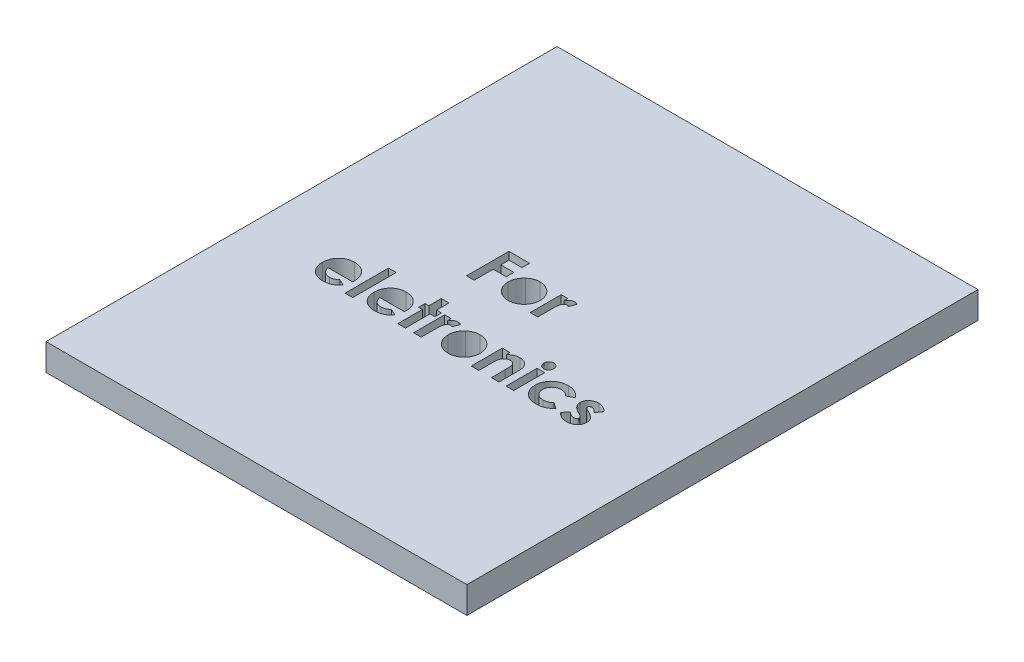
from build123d import *

# Parameters (mm, degrees)
SKETCH1_W           = 63
SKETCH1_H           = 81.5
BOSS_EXTRUDE1_DEPTH = 4
SKETCH2_W           = 1.13974359
SKETCH2_H           = 6.512820513
SKETCH2_H_2         = 4.640384615
CUT_EXTRUDE1_DEPTH  = 5
SKETCH3_W           = 63
SKETCH3_H           = 5
CUT_EXTRUDE2_DEPTH  = 5.0000001


with BuildPart() as part:
    # Sketch1 → Boss-Extrude1 (new body)
    with BuildSketch(Plane(origin=(0, 0, 0), x_dir=(1, 0, 0), z_dir=(0, 1, 0))):
        with Locations((-31.5, 40.75)):
            Rectangle(SKETCH1_W, SKETCH1_H)
    extrude(amount=BOSS_EXTRUDE1_DEPTH)

    # Sketch2 → Cut-Extrude1 (cut, through all)
    with BuildSketch(Plane(origin=(0, 4, 0), x_dir=(1, 0, 0), z_dir=(0, 1, 0))):
        Polygon((-40.055769231, 46.35), (-36.962179487, 46.35), (-36.962179487, 45.21025641), (-38.916025641, 45.21025641), (-38.916025641, 43.989102564), (-36.962179487, 43.989102564), (-36.962179487, 42.849358974), (-38.916025641, 42.849358974), (-38.916025641, 40), (-40.055769231, 40), align=None)
        with BuildLine():
            add(Edge.make_bspline(
                [(-33.774459135, 44.721794872), (-33.720574258, 44.720835954), (-33.613857786, 44.718936861), (-33.454916932, 44.703128649), (-33.298754731, 44.677336899), (-33.144473583, 44.643941085), (-32.993506133, 44.597148555), (-32.845060574, 44.541028151), (-32.697809615, 44.476595363), (-32.555407996, 44.399897809), (-32.41682697, 44.316712317), (-32.28544391, 44.224951894), (-32.162349862, 44.125337286), (-32.045259781, 44.020178138), (-31.939630254, 43.904896162), (-31.838710987, 43.785046127), (-31.747954402, 43.656334226), (-31.663926878, 43.52189687), (-31.589117778, 43.382511483), (-31.524159832, 43.239147681), (-31.467782443, 43.093787568), (-31.423640077, 42.944660559), (-31.387094267, 42.793733092), (-31.364031263, 42.639155664), (-31.347635066, 42.482516174), (-31.345796533, 42.377053579), (-31.344871795, 42.324008413)],
                knots=[0, 0, 0, 0, 0.000161629, 0.000320098, 0.000478613, 0.000636315, 0.000793245, 0.000952249, 0.001112273, 0.001275019, 0.001437107, 0.001596964, 0.001755296, 0.001911968, 0.002068568, 0.002223944, 0.002381722, 0.002540559, 0.002699339, 0.002855882, 0.003012508, 0.003166634, 0.00332214, 0.003477942, 0.003635146, 0.003794231, 0.003794231, 0.003794231, 0.003794231], degree=3))
            add(Edge.make_bspline(
                [(-31.344871795, 42.324008413), (-31.345847703, 42.270548833), (-31.347788029, 42.164259068), (-31.363438069, 42.006146189), (-31.389328541, 41.850841856), (-31.42285253, 41.697431143), (-31.469469949, 41.547877088), (-31.523937427, 41.399975204), (-31.5907984, 41.255741451), (-31.664718132, 41.113602373), (-31.749285917, 40.977740689), (-31.839963942, 40.847739406), (-31.940460509, 40.727009066), (-32.045244443, 40.611805488), (-32.159285882, 40.50602434), (-32.280764512, 40.407948017), (-32.408628665, 40.316377495), (-32.543797819, 40.233461189), (-32.684540684, 40.160605587), (-32.828483657, 40.094920317), (-32.976468437, 40.04023264), (-33.128188761, 39.995636345), (-33.283736643, 39.96110655), (-33.442768673, 39.937650049), (-33.604942355, 39.921336324), (-33.714208595, 39.919511164), (-33.769370994, 39.918589744)],
                knots=[0, 0, 0, 0, 0.000160357, 0.000318826, 0.000476086, 0.000632547, 0.000789477, 0.000945652, 0.001105038, 0.001266065, 0.001425982, 0.001584798, 0.001741155, 0.00189689, 0.002051692, 0.002207245, 0.002365023, 0.002523191, 0.002682501, 0.002840202, 0.00299757, 0.003155354, 0.003314297, 0.003475128, 0.003637396, 0.003802839, 0.003802839, 0.003802839, 0.003802839], degree=3))
            add(Edge.make_bspline(
                [(-33.769370994, 39.918589744), (-33.850029668, 39.920957235), (-34.009009143, 39.925623596), (-34.243148324, 39.957586948), (-34.468078786, 40.012604259), (-34.68416705, 40.089297176), (-34.891693822, 40.187576291), (-35.088847972, 40.309211621), (-35.277590648, 40.451808514), (-35.454652683, 40.614161729), (-35.616865495, 40.792277907), (-35.758577902, 40.982415842), (-35.878903203, 41.181725686), (-35.977733143, 41.390434719), (-36.054009704, 41.608829137), (-36.109094394, 41.836256018), (-36.141096826, 42.073354625), (-36.145723721, 42.234446258), (-36.148076923, 42.316376202)],
                knots=[0, 0, 0, 0, 0.000241958, 0.000476902, 0.000707365, 0.000935486, 0.001163649, 0.0013949, 0.00162921, 0.001872306, 0.002114544, 0.002350889, 0.002582568, 0.00281188, 0.003042399, 0.003275335, 0.0035128, 0.00375857, 0.00375857, 0.00375857, 0.00375857], degree=3))
            add(Edge.make_bspline(
                [(-36.148076923, 42.316376202), (-36.145641657, 42.403859422), (-36.140855192, 42.575805939), (-36.102848546, 42.827711506), (-36.042156033, 43.068899148), (-35.955035753, 43.298694186), (-35.843747258, 43.517520447), (-35.707889227, 43.724916402), (-35.546790242, 43.920929029), (-35.423420678, 44.039484185), (-35.360687099, 44.099769631)],
                knots=[0, 0, 0, 0, 0.000262348, 0.000515639, 0.000762454, 0.001007214, 0.001251266, 0.001497528, 0.001749652, 0.002010496, 0.002010496, 0.002010496, 0.002010496], degree=3))
            add(Edge.make_bspline(
                [(-35.360687099, 44.099769631), (-35.30312277, 44.149739485), (-35.189560266, 44.248319662), (-35.005058572, 44.373352456), (-34.816149657, 44.481342644), (-34.620569366, 44.570130664), (-34.417772471, 44.637075398), (-34.208798193, 44.685805175), (-33.993689983, 44.715736432), (-33.847907452, 44.719765129), (-33.774459135, 44.721794872)],
                knots=[0, 0, 0, 0, 0.000228503, 0.000450789, 0.000667259, 0.000880757, 0.001093951, 0.001306852, 0.001523808, 0.001744105, 0.001744105, 0.001744105, 0.001744105], degree=3))
        make_face()
        with BuildLine():
            Line((-30.530769231, 44.640384615), (-29.553846154, 44.640384615))
            Line((-29.553846154, 44.640384615), (-29.553846154, 44.069240785))
            add(Edge.make_bspline(
                [(-29.553846154, 44.069240785), (-29.526210875, 44.119998495), (-29.472196577, 44.219206543), (-29.372967782, 44.352373702), (-29.258969722, 44.464523368), (-29.134298701, 44.558001253), (-28.998576866, 44.630858085), (-28.855438606, 44.682777764), (-28.706108465, 44.71651836), (-28.604240505, 44.72002337), (-28.552754407, 44.721794872)],
                knots=[0, 0, 0, 0, 0.00017324, 0.000338604, 0.000496013, 0.000651457, 0.000804551, 0.000956265, 0.001107209, 0.001261461, 0.001261461, 0.001261461, 0.001261461], degree=3))
            add(Edge.make_bspline(
                [(-28.552754407, 44.721794872), (-28.515369076, 44.720044258), (-28.439239191, 44.716479383), (-28.323206534, 44.695756709), (-28.20549973, 44.658286175), (-28.12803851, 44.624548939), (-28.088461538, 44.607311699)],
                knots=[0, 0, 0, 0, 0.000112199, 0.000228477, 0.000352395, 0.000481849, 0.000481849, 0.000481849, 0.000481849], degree=3))
            Line((-28.088461538, 44.607311699), (-28.44208734, 43.641836939))
            add(Edge.make_bspline(
                [(-28.44208734, 43.641836939), (-28.473696437, 43.657108926), (-28.533109371, 43.685814384), (-28.619366635, 43.71968978), (-28.697648679, 43.740358892), (-28.747278057, 43.743442904), (-28.770272436, 43.744871795)],
                knots=[0, 0, 0, 0, 0.00010528, 0.000197885, 0.000277791, 0.000346775, 0.000346775, 0.000346775, 0.000346775], degree=3))
            add(Edge.make_bspline(
                [(-28.770272436, 43.744871795), (-28.791983601, 43.743924936), (-28.834693203, 43.742062303), (-28.897731382, 43.726100166), (-28.957100218, 43.698573954), (-29.015660695, 43.663310146), (-29.068793039, 43.614290815), (-29.121892564, 43.557542236), (-29.168686709, 43.487478566), (-29.218068103, 43.409494144), (-29.260114594, 43.314041281), (-29.296168165, 43.200090234), (-29.328292187, 43.06632251), (-29.350397899, 42.912027868), (-29.371763958, 42.738699375), (-29.384481561, 42.545064821), (-29.393960152, 42.331736498), (-29.394539704, 42.18282563), (-29.394841747, 42.105218349)],
                knots=[0, 0, 0, 0, 6.5073e-05, 0.00012801, 0.000193492, 0.00026091, 0.00033211, 0.000409547, 0.00049354, 0.000584292, 0.000686198, 0.000805268, 0.000942565, 0.001098367, 0.001272557, 0.001466412, 0.0016803, 0.001913096, 0.001913096, 0.001913096, 0.001913096], degree=3))
            Line((-29.394841747, 42.105218349), (-29.391025641, 41.878796074))
            Line((-29.391025641, 41.878796074), (-29.391025641, 40))
            Line((-29.391025641, 40), (-30.530769231, 40))
            Line((-30.530769231, 40), (-30.530769231, 44.640384615))
        make_face()
        with BuildLine():
            Line((-47.793559696, 30.696153846), (-51.453205128, 30.696153846))
            add(Edge.make_bspline(
                [(-51.453205128, 30.696153846), (-51.445743407, 30.653630842), (-51.431080535, 30.570069785), (-51.399239588, 30.448690099), (-51.358605765, 30.334303931), (-51.309908686, 30.226758376), (-51.253969385, 30.125484882), (-51.188720825, 30.030958461), (-51.114990624, 29.943262606), (-51.033205071, 29.862778452), (-50.944727382, 29.790662906), (-50.849986641, 29.727485128), (-50.748885083, 29.675683216), (-50.642581798, 29.632019579), (-50.530282456, 29.597433555), (-50.41182178, 29.573580232), (-50.287513793, 29.559489986), (-50.202831395, 29.557451994), (-50.159545272, 29.556410256)],
                knots=[0, 0, 0, 0, 0.000129479, 0.000254437, 0.000375941, 0.000493217, 0.000608243, 0.000722564, 0.000837223, 0.000951459, 0.001066288, 0.001179184, 0.001292402, 0.001406496, 0.001523586, 0.001644328, 0.001768507, 0.001898354, 0.001898354, 0.001898354, 0.001898354], degree=3))
            add(Edge.make_bspline(
                [(-50.159545272, 29.556410256), (-50.107295984, 29.557789688), (-50.004401749, 29.560506195), (-49.853660927, 29.58459758), (-49.707872595, 29.620986557), (-49.568416423, 29.67510002), (-49.433677031, 29.74246177), (-49.305872643, 29.826386221), (-49.182791064, 29.924420827), (-49.107696797, 29.999985864), (-49.069411058, 30.038511619)],
                knots=[0, 0, 0, 0, 0.000156646, 0.000308483, 0.000456881, 0.000606657, 0.000756272, 0.000907985, 0.001064529, 0.001227354, 0.001227354, 0.001227354, 0.001227354], degree=3))
            Line((-49.069411058, 30.038511619), (-48.115384615, 29.584395032))
            add(Edge.make_bspline(
                [(-48.115384615, 29.584395032), (-48.145421581, 29.542888555), (-48.204938724, 29.460644998), (-48.302098463, 29.344907072), (-48.403490837, 29.236918892), (-48.509191464, 29.137390713), (-48.6193344, 29.04660615), (-48.733613254, 28.963459283), (-48.853698164, 28.890182573), (-48.977188054, 28.823230936), (-49.106635688, 28.765833608), (-49.241682829, 28.716887193), (-49.381757474, 28.67264005), (-49.528628466, 28.638926151), (-49.681072809, 28.612238504), (-49.839455182, 28.593286739), (-50.003754709, 28.581581142), (-50.115428141, 28.580193457), (-50.172265625, 28.579487179)],
                knots=[0, 0, 0, 0, 0.000153664, 0.000304479, 0.000452959, 0.000597843, 0.000739702, 0.00088092, 0.001021421, 0.00116142, 0.001302071, 0.001445743, 0.001592199, 0.00174246, 0.001897424, 0.002056307, 0.002220798, 0.002391293, 0.002391293, 0.002391293, 0.002391293], degree=3))
            add(Edge.make_bspline(
                [(-50.172265625, 28.579487179), (-50.259709162, 28.58126989), (-50.430962288, 28.584761226), (-50.681450944, 28.617165821), (-50.919345691, 28.670896133), (-51.145318262, 28.743934239), (-51.358391852, 28.84036742), (-51.558671912, 28.958313201), (-51.748159526, 29.095510323), (-51.92106479, 29.25483819), (-52.078586587, 29.428257102), (-52.21694394, 29.61449717), (-52.332719402, 29.812257207), (-52.42779654, 30.020228395), (-52.501693795, 30.238943059), (-52.554969429, 30.46849664), (-52.587628031, 30.708779502), (-52.591155322, 30.872438953), (-52.592948718, 30.955649038)],
                knots=[0, 0, 0, 0, 0.000262237, 0.000513576, 0.000756131, 0.000993061, 0.001224771, 0.001456243, 0.001689299, 0.001925206, 0.002160258, 0.002391264, 0.002619898, 0.002846449, 0.003076139, 0.003311255, 0.003552503, 0.00380203, 0.00380203, 0.00380203, 0.00380203], degree=3))
            add(Edge.make_bspline(
                [(-52.592948718, 30.955649038), (-52.591137671, 31.040973599), (-52.587574518, 31.208845841), (-52.555250619, 31.454676944), (-52.501546506, 31.689233065), (-52.427433085, 31.912837215), (-52.333798279, 32.12618873), (-52.216549773, 32.327421042), (-52.078655247, 32.51723473), (-51.921700919, 32.694741828), (-51.748063175, 32.854961377), (-51.563556666, 32.997749013), (-51.366108275, 33.11672915), (-51.157951311, 33.212865027), (-50.940417221, 33.290973), (-50.710991617, 33.342947333), (-50.471420076, 33.377844986), (-50.307654246, 33.381058842), (-50.224419071, 33.382692308)],
                knots=[0, 0, 0, 0, 0.000255882, 0.000503435, 0.00074227, 0.000976784, 0.001209135, 0.001439966, 0.001674052, 0.001911946, 0.002149575, 0.00238186, 0.002610703, 0.002839475, 0.003068794, 0.003302672, 0.003544091, 0.003793618, 0.003793618, 0.003793618, 0.003793618], degree=3))
            add(Edge.make_bspline(
                [(-50.224419071, 33.382692308), (-50.13655662, 33.38088194), (-49.964047753, 33.377327468), (-49.711814521, 33.345185991), (-49.472340182, 33.291128039), (-49.24460444, 33.21872148), (-49.031515574, 33.119852295), (-48.828391376, 33.004808973), (-48.640103915, 32.864646231), (-48.464646249, 32.706098063), (-48.306259847, 32.530194365), (-48.167812582, 32.339109074), (-48.050010999, 32.134707069), (-47.954531647, 31.916159458), (-47.880710271, 31.684122341), (-47.827385321, 31.438897064), (-47.794975826, 31.179550909), (-47.79151417, 31.001961732), (-47.78974359, 30.911127804)],
                knots=[0, 0, 0, 0, 0.000263508, 0.000517371, 0.000761167, 0.000999306, 0.001232699, 0.001464632, 0.001698441, 0.001935289, 0.002173082, 0.002407167, 0.00264194, 0.00287946, 0.00312123, 0.003371236, 0.00363141, 0.003903816, 0.003903816, 0.003903816, 0.003903816], degree=3))
            Line((-47.78974359, 30.911127804), (-47.793559696, 30.696153846))
        make_face()
        with Locations((-46.324358974, 31.917307693)):
            Rectangle(SKETCH2_W, SKETCH2_H)
        with BuildLine():
            Line((-40.059585337, 30.696153846), (-43.719230769, 30.696153846))
            add(Edge.make_bspline(
                [(-43.719230769, 30.696153846), (-43.711769048, 30.653630842), (-43.697106176, 30.570069785), (-43.665265229, 30.448690099), (-43.624631406, 30.334303931), (-43.575934328, 30.226758376), (-43.519995026, 30.125484882), (-43.454746466, 30.030958461), (-43.381016265, 29.943262606), (-43.299230712, 29.862778452), (-43.210753023, 29.790662906), (-43.116012282, 29.727485128), (-43.014910724, 29.675683216), (-42.908607439, 29.632019579), (-42.796308097, 29.597433555), (-42.677847421, 29.573580232), (-42.553539434, 29.559489986), (-42.468857036, 29.557451994), (-42.425570913, 29.556410256)],
                knots=[0, 0, 0, 0, 0.000129479, 0.000254437, 0.000375941, 0.000493217, 0.000608243, 0.000722564, 0.000837223, 0.000951459, 0.001066288, 0.001179184, 0.001292402, 0.001406496, 0.001523586, 0.001644328, 0.001768507, 0.001898354, 0.001898354, 0.001898354, 0.001898354], degree=3))
            add(Edge.make_bspline(
                [(-42.425570913, 29.556410256), (-42.373321625, 29.557789688), (-42.27042739, 29.560506195), (-42.119686569, 29.58459758), (-41.973898236, 29.620986557), (-41.834442065, 29.67510002), (-41.699702672, 29.74246177), (-41.571898284, 29.826386221), (-41.448816705, 29.924420827), (-41.373722438, 29.999985864), (-41.335436699, 30.038511619)],
                knots=[0, 0, 0, 0, 0.000156646, 0.000308483, 0.000456881, 0.000606657, 0.000756272, 0.000907985, 0.001064529, 0.001227354, 0.001227354, 0.001227354, 0.001227354], degree=3))
            Line((-41.335436699, 30.038511619), (-40.381410256, 29.584395032))
            add(Edge.make_bspline(
                [(-40.381410256, 29.584395032), (-40.411447222, 29.542888555), (-40.470964365, 29.460644998), (-40.568124104, 29.344907072), (-40.669516478, 29.236918892), (-40.775217105, 29.137390713), (-40.885360041, 29.04660615), (-40.999638895, 28.963459283), (-41.119723805, 28.890182573), (-41.243213695, 28.823230936), (-41.372661329, 28.765833608), (-41.50770847, 28.716887193), (-41.647783115, 28.67264005), (-41.794654107, 28.638926151), (-41.94709845, 28.612238504), (-42.105480823, 28.593286739), (-42.26978035, 28.581581142), (-42.381453782, 28.580193457), (-42.438291266, 28.579487179)],
                knots=[0, 0, 0, 0, 0.000153664, 0.000304479, 0.000452959, 0.000597843, 0.000739702, 0.00088092, 0.001021421, 0.00116142, 0.001302071, 0.001445743, 0.001592199, 0.00174246, 0.001897424, 0.002056307, 0.002220798, 0.002391293, 0.002391293, 0.002391293, 0.002391293], degree=3))
            add(Edge.make_bspline(
                [(-42.438291266, 28.579487179), (-42.525734803, 28.58126989), (-42.696987929, 28.584761226), (-42.947476585, 28.617165821), (-43.185371332, 28.670896133), (-43.411343903, 28.743934239), (-43.624417493, 28.84036742), (-43.824697553, 28.958313201), (-44.014185167, 29.095510323), (-44.187090431, 29.25483819), (-44.344612228, 29.428257102), (-44.482969581, 29.61449717), (-44.598745043, 29.812257207), (-44.693822181, 30.020228395), (-44.767719436, 30.238943059), (-44.82099507, 30.46849664), (-44.853653672, 30.708779502), (-44.857180963, 30.872438953), (-44.858974359, 30.955649038)],
                knots=[0, 0, 0, 0, 0.000262237, 0.000513576, 0.000756131, 0.000993061, 0.001224771, 0.001456243, 0.001689299, 0.001925206, 0.002160258, 0.002391264, 0.002619898, 0.002846449, 0.003076139, 0.003311255, 0.003552503, 0.00380203, 0.00380203, 0.00380203, 0.00380203], degree=3))
            add(Edge.make_bspline(
                [(-44.858974359, 30.955649038), (-44.857163312, 31.040973599), (-44.853600159, 31.208845841), (-44.82127626, 31.454676944), (-44.767572147, 31.689233065), (-44.693458726, 31.912837215), (-44.59982392, 32.12618873), (-44.482575414, 32.327421042), (-44.344680888, 32.51723473), (-44.18772656, 32.694741828), (-44.014088816, 32.854961377), (-43.829582307, 32.997749013), (-43.632133916, 33.11672915), (-43.423976952, 33.212865027), (-43.206442862, 33.290973), (-42.977017258, 33.342947333), (-42.737445717, 33.377844986), (-42.573679887, 33.381058842), (-42.490444712, 33.382692308)],
                knots=[0, 0, 0, 0, 0.000255882, 0.000503435, 0.00074227, 0.000976784, 0.001209135, 0.001439966, 0.001674052, 0.001911946, 0.002149575, 0.00238186, 0.002610703, 0.002839475, 0.003068794, 0.003302672, 0.003544091, 0.003793618, 0.003793618, 0.003793618, 0.003793618], degree=3))
            add(Edge.make_bspline(
                [(-42.490444712, 33.382692308), (-42.402582261, 33.38088194), (-42.230073394, 33.377327468), (-41.977840162, 33.345185991), (-41.738365823, 33.291128039), (-41.510630081, 33.21872148), (-41.297541215, 33.119852295), (-41.094417017, 33.004808973), (-40.906129556, 32.864646231), (-40.730671891, 32.706098063), (-40.572285488, 32.530194365), (-40.433838223, 32.339109074), (-40.31603664, 32.134707069), (-40.220557288, 31.916159458), (-40.146735912, 31.684122341), (-40.093410962, 31.438897064), (-40.061001467, 31.179550909), (-40.057539811, 31.001961732), (-40.055769231, 30.911127804)],
                knots=[0, 0, 0, 0, 0.000263508, 0.000517371, 0.000761167, 0.000999306, 0.001232699, 0.001464632, 0.001698441, 0.001935289, 0.002173082, 0.002407167, 0.00264194, 0.00287946, 0.00312123, 0.003371236, 0.00363141, 0.003903816, 0.003903816, 0.003903816, 0.003903816], degree=3))
            Line((-40.055769231, 30.911127804), (-40.059585337, 30.696153846))
        make_face()
        Polygon((-38.997435897, 35.173717949), (-37.857692308, 35.173717949), (-37.857692308, 33.301282051), (-37.125, 33.301282051), (-37.125, 32.324358974), (-37.857692308, 32.324358974), (-37.857692308, 28.660897436), (-38.997435897, 28.660897436), (-38.997435897, 32.324358974), (-39.567307692, 32.324358974), (-39.567307692, 33.301282051), (-38.997435897, 33.301282051), align=None)
        with BuildLine():
            Line((-36.636538462, 33.301282051), (-35.659615385, 33.301282051))
            Line((-35.659615385, 33.301282051), (-35.659615385, 32.730138221))
            add(Edge.make_bspline(
                [(-35.659615385, 32.730138221), (-35.631980106, 32.78089593), (-35.577965808, 32.880103979), (-35.478737012, 33.013271138), (-35.364738953, 33.125420804), (-35.240067932, 33.218898689), (-35.104346097, 33.291755521), (-34.961207836, 33.3436752), (-34.811877695, 33.377415796), (-34.710009736, 33.380920806), (-34.658523638, 33.382692308)],
                knots=[0, 0, 0, 0, 0.00017324, 0.000338604, 0.000496013, 0.000651457, 0.000804551, 0.000956265, 0.001107209, 0.001261461, 0.001261461, 0.001261461, 0.001261461], degree=3))
            add(Edge.make_bspline(
                [(-34.658523638, 33.382692308), (-34.621138306, 33.380941694), (-34.545008422, 33.377376819), (-34.428975765, 33.356654145), (-34.311268961, 33.319183611), (-34.233807741, 33.285446375), (-34.194230769, 33.268209135)],
                knots=[0, 0, 0, 0, 0.000112199, 0.000228477, 0.000352395, 0.000481849, 0.000481849, 0.000481849, 0.000481849], degree=3))
            Line((-34.194230769, 33.268209135), (-34.547856571, 32.302734375))
            add(Edge.make_bspline(
                [(-34.547856571, 32.302734375), (-34.579465667, 32.318006362), (-34.638878601, 32.346711819), (-34.725135866, 32.380587216), (-34.803417909, 32.401256328), (-34.853047288, 32.40434034), (-34.876041667, 32.405769231)],
                knots=[0, 0, 0, 0, 0.00010528, 0.000197885, 0.000277791, 0.000346775, 0.000346775, 0.000346775, 0.000346775], degree=3))
            add(Edge.make_bspline(
                [(-34.876041667, 32.405769231), (-34.897752832, 32.404822372), (-34.940462434, 32.402959739), (-35.003500612, 32.386997601), (-35.062869449, 32.35947139), (-35.121429926, 32.324207582), (-35.17456227, 32.275188251), (-35.227661795, 32.218439671), (-35.27445594, 32.148376002), (-35.323837334, 32.07039158), (-35.365883825, 31.974938717), (-35.401937396, 31.86098767), (-35.434061418, 31.727219946), (-35.45616713, 31.572925304), (-35.477533189, 31.399596811), (-35.490250792, 31.205962257), (-35.499729382, 30.992633934), (-35.500308935, 30.843723066), (-35.500610978, 30.766115785)],
                knots=[0, 0, 0, 0, 6.5073e-05, 0.00012801, 0.000193492, 0.00026091, 0.00033211, 0.000409547, 0.00049354, 0.000584292, 0.000686198, 0.000805268, 0.000942565, 0.001098367, 0.001272557, 0.001466412, 0.0016803, 0.001913096, 0.001913096, 0.001913096, 0.001913096], degree=3))
            Line((-35.500610978, 30.766115785), (-35.496794872, 30.53969351))
            Line((-35.496794872, 30.53969351), (-35.496794872, 28.660897436))
            Line((-35.496794872, 28.660897436), (-36.636538462, 28.660897436))
            Line((-36.636538462, 28.660897436), (-36.636538462, 33.301282051))
        make_face()
        with BuildLine():
            add(Edge.make_bspline(
                [(-31.413561699, 33.382692308), (-31.359676822, 33.381733389), (-31.25296035, 33.379834297), (-31.094019496, 33.364026085), (-30.937857295, 33.338234335), (-30.783576147, 33.304838521), (-30.632608697, 33.258045991), (-30.484163138, 33.201925587), (-30.336912179, 33.137492799), (-30.19451056, 33.060795245), (-30.055929534, 32.977609753), (-29.924546474, 32.88584933), (-29.801452426, 32.786234722), (-29.684362345, 32.681075573), (-29.578732818, 32.565793598), (-29.477813551, 32.445943563), (-29.387056966, 32.317231662), (-29.303029442, 32.182794306), (-29.228220342, 32.043408919), (-29.163262397, 31.900045117), (-29.106885007, 31.754685004), (-29.062742641, 31.605557995), (-29.026196831, 31.454630528), (-29.003133827, 31.3000531), (-28.986737631, 31.14341361), (-28.984899097, 31.037951014), (-28.983974359, 30.984905849)],
                knots=[0, 0, 0, 0, 0.000161629, 0.000320098, 0.000478613, 0.000636315, 0.000793245, 0.000952249, 0.001112273, 0.001275019, 0.001437107, 0.001596964, 0.001755296, 0.001911968, 0.002068568, 0.002223944, 0.002381722, 0.002540559, 0.002699339, 0.002855882, 0.003012508, 0.003166634, 0.00332214, 0.003477942, 0.003635146, 0.003794231, 0.003794231, 0.003794231, 0.003794231], degree=3))
            add(Edge.make_bspline(
                [(-28.983974359, 30.984905849), (-28.984950267, 30.931446269), (-28.986890594, 30.825156504), (-29.002540633, 30.667043625), (-29.028431105, 30.511739292), (-29.061955094, 30.358328579), (-29.108572513, 30.208774524), (-29.163039992, 30.06087264), (-29.229900964, 29.916638887), (-29.303820696, 29.774499809), (-29.388388481, 29.638638125), (-29.479066506, 29.508636841), (-29.579563073, 29.387906502), (-29.684347007, 29.272702924), (-29.798388446, 29.166921775), (-29.919867076, 29.068845453), (-30.047731229, 28.977274931), (-30.182900383, 28.894358625), (-30.323643248, 28.821503023), (-30.467586221, 28.755817753), (-30.615571001, 28.701130076), (-30.767291326, 28.656533781), (-30.922839207, 28.622003986), (-31.081871237, 28.598547485), (-31.244044919, 28.58223376), (-31.35331116, 28.5804086), (-31.408473558, 28.579487179)],
                knots=[0, 0, 0, 0, 0.000160357, 0.000318826, 0.000476086, 0.000632547, 0.000789477, 0.000945652, 0.001105038, 0.001266065, 0.001425982, 0.001584798, 0.001741155, 0.00189689, 0.002051692, 0.002207245, 0.002365023, 0.002523191, 0.002682501, 0.002840202, 0.00299757, 0.003155354, 0.003314297, 0.003475128, 0.003637396, 0.003802839, 0.003802839, 0.003802839, 0.003802839], degree=3))
            add(Edge.make_bspline(
                [(-31.408473558, 28.579487179), (-31.489132232, 28.581854671), (-31.648111707, 28.586521032), (-31.882250888, 28.618484384), (-32.10718135, 28.673501695), (-32.323269614, 28.750194612), (-32.530796386, 28.848473727), (-32.727950536, 28.970109057), (-32.916693212, 29.11270595), (-33.093755248, 29.275059165), (-33.255968059, 29.453175343), (-33.397680466, 29.643313278), (-33.518005768, 29.842623122), (-33.616835707, 30.051332154), (-33.693112268, 30.269726573), (-33.748196959, 30.497153453), (-33.78019939, 30.734252061), (-33.784826285, 30.895343694), (-33.787179487, 30.977273638)],
                knots=[0, 0, 0, 0, 0.000241958, 0.000476902, 0.000707365, 0.000935486, 0.001163649, 0.0013949, 0.00162921, 0.001872306, 0.002114544, 0.002350889, 0.002582568, 0.00281188, 0.003042399, 0.003275335, 0.0035128, 0.00375857, 0.00375857, 0.00375857, 0.00375857], degree=3))
            add(Edge.make_bspline(
                [(-33.787179487, 30.977273638), (-33.784744222, 31.064756858), (-33.779957756, 31.236703375), (-33.74195111, 31.488608942), (-33.681258597, 31.729796583), (-33.594138317, 31.959591622), (-33.482849822, 32.178417883), (-33.346991792, 32.385813838), (-33.185892806, 32.581826465), (-33.062523242, 32.700381621), (-32.999789663, 32.760667067)],
                knots=[0, 0, 0, 0, 0.000262348, 0.000515639, 0.000762454, 0.001007214, 0.001251266, 0.001497528, 0.001749652, 0.002010496, 0.002010496, 0.002010496, 0.002010496], degree=3))
            add(Edge.make_bspline(
                [(-32.999789663, 32.760667067), (-32.942225334, 32.810636921), (-32.82866283, 32.909217098), (-32.644161136, 33.034249892), (-32.455252221, 33.14224008), (-32.25967193, 33.2310281), (-32.056875036, 33.297972834), (-31.847900757, 33.346702611), (-31.632792547, 33.376633868), (-31.487010017, 33.380662565), (-31.413561699, 33.382692308)],
                knots=[0, 0, 0, 0, 0.000228503, 0.000450789, 0.000667259, 0.000880757, 0.001093951, 0.001306852, 0.001523808, 0.001744105, 0.001744105, 0.001744105, 0.001744105], degree=3))
        make_face()
        with BuildLine():
            Line((-28.007051282, 33.301282051), (-26.867307692, 33.301282051))
            Line((-26.867307692, 33.301282051), (-26.867307692, 32.810276442))
            add(Edge.make_bspline(
                [(-26.867307692, 32.810276442), (-26.802285886, 32.860851743), (-26.678016573, 32.957510974), (-26.489105761, 33.080751986), (-26.310797345, 33.181619805), (-26.139116636, 33.25834503), (-25.97083346, 33.313545531), (-25.803222349, 33.353203797), (-25.633787234, 33.378598075), (-25.519885708, 33.381328296), (-25.462980769, 33.382692308)],
                knots=[0, 0, 0, 0, 0.00024703, 0.000472123, 0.000675982, 0.000861062, 0.001035238, 0.001206477, 0.001377376, 0.001547999, 0.001547999, 0.001547999, 0.001547999], degree=3))
            add(Edge.make_bspline(
                [(-25.462980769, 33.382692308), (-25.405258366, 33.381133525), (-25.291944441, 33.378073502), (-25.125095931, 33.356671126), (-24.965688383, 33.317690618), (-24.81192939, 33.265935047), (-24.665383957, 33.197620662), (-24.524256812, 33.116508413), (-24.391579316, 33.017708206), (-24.309870641, 32.942466712), (-24.268539663, 32.904407051)],
                knots=[0, 0, 0, 0, 0.000173165, 0.000339938, 0.000503457, 0.000664765, 0.000825837, 0.000987721, 0.001152325, 0.001320816, 0.001320816, 0.001320816, 0.001320816], degree=3))
            add(Edge.make_bspline(
                [(-24.268539663, 32.904407051), (-24.235390698, 32.869136875), (-24.168850158, 32.798338388), (-24.085117247, 32.677184042), (-24.013264991, 32.54510363), (-23.954392052, 32.40057356), (-23.910887321, 32.242799734), (-23.877418539, 32.073687835), (-23.858638621, 31.892290959), (-23.856320152, 31.767673017), (-23.855128205, 31.703605769)],
                knots=[0, 0, 0, 0, 0.00014504, 0.000291141, 0.000440274, 0.000595467, 0.000758138, 0.000930522, 0.001112156, 0.001304338, 0.001304338, 0.001304338, 0.001304338], degree=3))
            Line((-23.855128205, 31.703605769), (-23.855128205, 28.660897436))
            Line((-23.855128205, 28.660897436), (-24.994871795, 28.660897436))
            Line((-24.994871795, 28.660897436), (-24.994871795, 30.675801282))
            add(Edge.make_bspline(
                [(-24.994871795, 30.675801282), (-24.995112825, 30.741523935), (-24.995574716, 30.867469202), (-24.999121012, 31.047715806), (-25.006045449, 31.210501897), (-25.012356892, 31.356123861), (-25.024748764, 31.484064642), (-25.035923955, 31.595134204), (-25.053071202, 31.688324915), (-25.075382551, 31.788565507), (-25.114343663, 31.895891391), (-25.17482889, 32.008976941), (-25.251562882, 32.105045637), (-25.341411516, 32.184770969), (-25.444275563, 32.247841018), (-25.558912059, 32.292214727), (-25.684706416, 32.319869511), (-25.772358446, 32.322824412), (-25.817878606, 32.324358974)],
                knots=[0, 0, 0, 0, 0.00019717, 0.000377839, 0.000540784, 0.000685996, 0.000814981, 0.000926377, 0.001020696, 0.001099068, 0.001234264, 0.001361772, 0.001482159, 0.001601107, 0.001720441, 0.001842092, 0.001968337, 0.002104736, 0.002104736, 0.002104736, 0.002104736], degree=3))
            add(Edge.make_bspline(
                [(-25.817878606, 32.324358974), (-25.877079488, 32.321356882), (-25.992887922, 32.315484205), (-26.160381655, 32.271198865), (-26.314221857, 32.195882538), (-26.453151529, 32.091659885), (-26.575847481, 31.962984106), (-26.676903122, 31.809523478), (-26.759789508, 31.634981765), (-26.795431886, 31.507537964), (-26.813882212, 31.441566506)],
                knots=[0, 0, 0, 0, 0.000177471, 0.000347167, 0.000515562, 0.000688306, 0.000865557, 0.001046191, 0.001237386, 0.001442574, 0.001442574, 0.001442574, 0.001442574], degree=3))
            add(Edge.make_bspline(
                [(-26.813882212, 31.441566506), (-26.81846785, 31.420847728), (-26.828694747, 31.374640687), (-26.837105076, 31.296578942), (-26.848804454, 31.203966239), (-26.853187923, 31.095126549), (-26.860810294, 30.970574965), (-26.863629411, 30.830146709), (-26.866453572, 30.674117136), (-26.867013553, 30.565136408), (-26.867307692, 30.507892628)],
                knots=[0, 0, 0, 0, 6.3614e-05, 0.000141873, 0.000235288, 0.000343597, 0.000468419, 0.000609667, 0.000764876, 0.000936605, 0.000936605, 0.000936605, 0.000936605], degree=3))
            Line((-26.867307692, 30.507892628), (-26.867307692, 28.660897436))
            Line((-26.867307692, 28.660897436), (-28.007051282, 28.660897436))
            Line((-28.007051282, 28.660897436), (-28.007051282, 33.301282051))
        make_face()
        with BuildLine():
            add(Edge.make_bspline(
                [(-22.229467147, 35.255128205), (-22.180344207, 35.252718048), (-22.08388658, 35.247985471), (-21.945697904, 35.201853381), (-21.818868705, 35.129450443), (-21.706748175, 35.030111886), (-21.613496804, 34.91148348), (-21.542249292, 34.778671092), (-21.502560272, 34.631519243), (-21.497048054, 34.529868286), (-21.494230769, 34.477914663)],
                knots=[0, 0, 0, 0, 0.000146952, 0.000288554, 0.000432131, 0.000582667, 0.000734844, 0.000882778, 0.001031829, 0.001187646, 0.001187646, 0.001187646, 0.001187646], degree=3))
            add(Edge.make_bspline(
                [(-21.494230769, 34.477914663), (-21.496947256, 34.426343911), (-21.50224046, 34.325855843), (-21.54316276, 34.180701649), (-21.611550643, 34.047953769), (-21.705557293, 33.931087215), (-21.816462289, 33.833348564), (-21.940520173, 33.759631194), (-22.077384601, 33.716065421), (-22.172345497, 33.710937228), (-22.220562901, 33.708333333)],
                knots=[0, 0, 0, 0, 0.000154551, 0.00030115, 0.000448498, 0.000599677, 0.000748418, 0.000889792, 0.001029797, 0.001174216, 0.001174216, 0.001174216, 0.001174216], degree=3))
            add(Edge.make_bspline(
                [(-22.220562901, 33.708333333), (-22.270114644, 33.710734875), (-22.367411448, 33.715450396), (-22.506733556, 33.761690426), (-22.635254333, 33.833523144), (-22.746888484, 33.934891341), (-22.841207792, 34.054362692), (-22.909343184, 34.190267067), (-22.951963557, 34.338425136), (-22.957022558, 34.441581614), (-22.959615385, 34.494451122)],
                knots=[0, 0, 0, 0, 0.000148218, 0.000291032, 0.000435714, 0.000587092, 0.000740271, 0.000889885, 0.001040502, 0.001198853, 0.001198853, 0.001198853, 0.001198853], degree=3))
            add(Edge.make_bspline(
                [(-22.959615385, 34.494451122), (-22.95679368, 34.545146172), (-22.951250849, 34.644729281), (-22.911324087, 34.788609513), (-22.841710279, 34.919189116), (-22.749130605, 35.035645918), (-22.637994872, 35.133131438), (-22.511241811, 35.203335451), (-22.373983149, 35.247562155), (-22.278136547, 35.252580147), (-22.229467147, 35.255128205)],
                knots=[0, 0, 0, 0, 0.000152018, 0.000298616, 0.000443707, 0.000593099, 0.0007428, 0.000884019, 0.001025237, 0.001170923, 0.001170923, 0.001170923, 0.001170923], degree=3))
        make_face()
        with Locations((-22.226923077, 30.981089744)):
            Rectangle(SKETCH2_W, SKETCH2_H_2)
        with BuildLine():
            Line((-16.121153846, 32.354887821), (-17.065004006, 31.835897436))
            add(Edge.make_bspline(
                [(-17.065004006, 31.835897436), (-17.108266658, 31.87922117), (-17.19142835, 31.962500277), (-17.324784808, 32.067918416), (-17.45575836, 32.155201702), (-17.589748506, 32.219612284), (-17.727952957, 32.268119626), (-17.875356581, 32.300247104), (-18.033679836, 32.321401907), (-18.143192212, 32.323352962), (-18.199659455, 32.324358974)],
                knots=[0, 0, 0, 0, 0.000183526, 0.000352783, 0.000509083, 0.000654724, 0.000797538, 0.000947514, 0.001106554, 0.001275855, 0.001275855, 0.001275855, 0.001275855], degree=3))
            add(Edge.make_bspline(
                [(-18.199659455, 32.324358974), (-18.251443814, 32.323108191), (-18.352781463, 32.320660513), (-18.500851849, 32.302378035), (-18.641577577, 32.273663234), (-18.774706038, 32.23165338), (-18.900000115, 32.176156075), (-19.018495939, 32.110483364), (-19.129042039, 32.032070158), (-19.230075819, 31.94203108), (-19.321276562, 31.842900052), (-19.402632279, 31.73717255), (-19.469281823, 31.623280131), (-19.526904488, 31.503899682), (-19.569269374, 31.376788969), (-19.600264555, 31.243101391), (-19.61793152, 31.102831024), (-19.620491151, 31.007002399), (-19.621794872, 30.958193109)],
                knots=[0, 0, 0, 0, 0.000155319, 0.000303945, 0.000446895, 0.000585687, 0.000721819, 0.000857355, 0.000991474, 0.001127535, 0.001262562, 0.00139511, 0.001526875, 0.001657746, 0.001792101, 0.00192787, 0.002068922, 0.002215345, 0.002215345, 0.002215345, 0.002215345], degree=3))
            add(Edge.make_bspline(
                [(-19.621794872, 30.958193109), (-19.620417378, 30.910657581), (-19.617727725, 30.817841094), (-19.6012034, 30.681471557), (-19.572516551, 30.551653576), (-19.529504375, 30.429073463), (-19.477949474, 30.312601201), (-19.413205956, 30.203163118), (-19.337071146, 30.100281326), (-19.249144225, 30.004850017), (-19.151743508, 29.919021264), (-19.046737899, 29.843225588), (-18.93444069, 29.778964878), (-18.813543731, 29.728534663), (-18.686018126, 29.687444587), (-18.551012254, 29.658186845), (-18.408669783, 29.641946774), (-18.311638524, 29.639217195), (-18.261989183, 29.637820513)],
                knots=[0, 0, 0, 0, 0.00014261, 0.000278456, 0.000411461, 0.00054059, 0.000667552, 0.000792994, 0.000921217, 0.001050853, 0.001181526, 0.001310027, 0.001438773, 0.00156872, 0.001702277, 0.001840251, 0.001982412, 0.002131376, 0.002131376, 0.002131376, 0.002131376], degree=3))
            add(Edge.make_bspline(
                [(-18.261989183, 29.637820513), (-18.200858944, 29.639219351), (-18.081541601, 29.641949681), (-17.908088812, 29.66510746), (-17.744872111, 29.703402283), (-17.591874188, 29.756405359), (-17.449309093, 29.82570787), (-17.317543133, 29.910355716), (-17.19522176, 30.009724463), (-17.123890675, 30.087194577), (-17.087900641, 30.126282051)],
                knots=[0, 0, 0, 0, 0.000183332, 0.000357837, 0.000523832, 0.000685556, 0.000842573, 0.000998183, 0.00115454, 0.001313768, 0.001313768, 0.001313768, 0.001313768], degree=3))
            Line((-17.087900641, 30.126282051), (-16.202564103, 29.518249199))
            add(Edge.make_bspline(
                [(-16.202564103, 29.518249199), (-16.263931379, 29.443219943), (-16.385035033, 29.295155413), (-16.596327326, 29.104305638), (-16.823741653, 28.940323274), (-17.071851807, 28.80943463), (-17.337044484, 28.705329446), (-17.62139191, 28.631737416), (-17.92441313, 28.588416924), (-18.132522773, 28.582511339), (-18.239092548, 28.579487179)],
                knots=[0, 0, 0, 0, 0.000290431, 0.000573144, 0.000851289, 0.001129566, 0.001412318, 0.001704189, 0.002008747, 0.002328393, 0.002328393, 0.002328393, 0.002328393], degree=3))
            add(Edge.make_bspline(
                [(-18.239092548, 28.579487179), (-18.335011955, 28.581704552), (-18.522353132, 28.586035324), (-18.795398244, 28.619200867), (-19.052211349, 28.675063711), (-19.293320753, 28.752645719), (-19.518506633, 28.85314347), (-19.727038692, 28.977798233), (-19.920323473, 29.123142564), (-20.094873345, 29.289863066), (-20.250611881, 29.471340132), (-20.386572185, 29.662464336), (-20.504156875, 29.85981129), (-20.596401949, 30.066665757), (-20.671791598, 30.27980356), (-20.722707401, 30.501772456), (-20.756289508, 30.730744061), (-20.759774728, 30.885989589), (-20.761538462, 30.964553285)],
                knots=[0, 0, 0, 0, 0.000287708, 0.000561925, 0.000823659, 0.001075075, 0.001320472, 0.00156175, 0.00180242, 0.002044458, 0.002284391, 0.002518767, 0.002747401, 0.002972267, 0.003197144, 0.00342454, 0.003654444, 0.00388999, 0.00388999, 0.00388999, 0.00388999], degree=3))
            add(Edge.make_bspline(
                [(-20.761538462, 30.964553285), (-20.760593617, 31.019289279), (-20.75872217, 31.127704452), (-20.74274593, 31.288713075), (-20.717892269, 31.446989446), (-20.680540151, 31.601422548), (-20.63460364, 31.752761633), (-20.57876159, 31.900976282), (-20.510811386, 32.04530168), (-20.435012726, 32.186965547), (-20.348623364, 32.322228164), (-20.254374362, 32.451029835), (-20.152398509, 32.572581708), (-20.041497846, 32.685750953), (-19.922445642, 32.791347341), (-19.796972609, 32.891513227), (-19.6610185, 32.981082826), (-19.519309605, 33.065294794), (-19.370625247, 33.140259664), (-19.216674352, 33.204964231), (-19.058646614, 33.259940092), (-18.896163249, 33.304141794), (-18.72992167, 33.3405721), (-18.558442619, 33.363692269), (-18.383144797, 33.379942941), (-18.264571844, 33.381770327), (-18.204747596, 33.382692308)],
                knots=[0, 0, 0, 0, 0.000164171, 0.000325173, 0.000484944, 0.000644456, 0.000801387, 0.000959201, 0.001119119, 0.001279622, 0.00144089, 0.001600159, 0.001758142, 0.001916458, 0.002075019, 0.002235341, 0.002397629, 0.002562994, 0.002729674, 0.002896703, 0.00306365, 0.003231221, 0.003401622, 0.00357378, 0.003749983, 0.003929412, 0.003929412, 0.003929412, 0.003929412], degree=3))
            add(Edge.make_bspline(
                [(-18.204747596, 33.382692308), (-18.149178545, 33.382064052), (-18.039584627, 33.380825), (-17.877739183, 33.367868984), (-17.720308553, 33.345862622), (-17.567024821, 33.316749131), (-17.417422466, 33.280672447), (-17.273506555, 33.232583435), (-17.133309517, 33.178004217), (-16.95273425, 33.095595297), (-16.739869061, 32.972586645), (-16.506200113, 32.796165122), (-16.297855959, 32.589777671), (-16.180367614, 32.433600593), (-16.121153846, 32.354887821)],
                knots=[0, 0, 0, 0, 0.00016668, 0.000328729, 0.000486676, 0.000643349, 0.00079668, 0.00094793, 0.001098164, 0.001247865, 0.001543068, 0.001833605, 0.002124133, 0.002419344, 0.002419344, 0.002419344, 0.002419344], degree=3))
        make_face()
        with BuildLine():
            Line((-12.132051282, 32.585126202), (-12.829126603, 31.835897436))
            add(Edge.make_bspline(
                [(-12.829126603, 31.835897436), (-12.863934913, 31.874414718), (-12.930510025, 31.948083689), (-13.032430086, 32.048510961), (-13.13283236, 32.132137212), (-13.229845856, 32.202386748), (-13.325451937, 32.256259745), (-13.418855902, 32.295020159), (-13.510102565, 32.319625847), (-13.570584711, 32.32281096), (-13.599979968, 32.324358974)],
                knots=[0, 0, 0, 0, 0.000155735, 0.000297862, 0.000428807, 0.0005474, 0.000656743, 0.000757137, 0.000850309, 0.000938411, 0.000938411, 0.000938411, 0.000938411], degree=3))
            add(Edge.make_bspline(
                [(-13.599979968, 32.324358974), (-13.629725015, 32.323452447), (-13.686677528, 32.32171673), (-13.767050285, 32.306828627), (-13.837663128, 32.281054578), (-13.897414101, 32.245922146), (-13.945419089, 32.202642599), (-13.97902962, 32.153131818), (-14.001599401, 32.098929705), (-14.003508658, 32.06042785), (-14.004487179, 32.040695112)],
                knots=[0, 0, 0, 0, 8.9188e-05, 0.000170767, 0.000244017, 0.000313607, 0.000377526, 0.000436095, 0.000492079, 0.000550938, 0.000550938, 0.000550938, 0.000550938], degree=3))
            add(Edge.make_bspline(
                [(-14.004487179, 32.040695112), (-14.00117186, 32.010791485), (-13.994292959, 31.948744933), (-13.947044443, 31.876780189), (-13.884531245, 31.82369327), (-13.812471603, 31.774292844), (-13.714884193, 31.719057879), (-13.640851907, 31.681236884), (-13.599979968, 31.660356571)],
                knots=[0, 0, 0, 0, 8.9315e-05, 0.000185317, 0.000248383, 0.000335189, 0.000446897, 0.000584583, 0.000584583, 0.000584583, 0.000584583], degree=3))
            Line((-13.599979968, 31.660356571), (-13.187840545, 31.451742788))
            add(Edge.make_bspline(
                [(-13.187840545, 31.451742788), (-13.13540853, 31.425119515), (-13.033680572, 31.373465362), (-12.890660593, 31.290114451), (-12.758565061, 31.209324761), (-12.640043772, 31.126526242), (-12.534371301, 31.043157381), (-12.442298234, 30.958393769), (-12.361591335, 30.874922572), (-12.271591815, 30.763010518), (-12.181565283, 30.613952768), (-12.106511115, 30.420110109), (-12.058649985, 30.212547244), (-12.053354703, 30.068885069), (-12.050641026, 29.99526242)],
                knots=[0, 0, 0, 0, 0.000176373, 0.000342197, 0.000496449, 0.000640779, 0.000775669, 0.000899912, 0.001015974, 0.001123648, 0.001330239, 0.001535273, 0.001745128, 0.001965719, 0.001965719, 0.001965719, 0.001965719], degree=3))
            add(Edge.make_bspline(
                [(-12.050641026, 29.99526242), (-12.052276033, 29.94559345), (-12.055476178, 29.848378095), (-12.075706814, 29.70528636), (-12.112046276, 29.569227307), (-12.159868953, 29.438080045), (-12.224284666, 29.314216118), (-12.302488497, 29.197035076), (-12.39324558, 29.084998396), (-12.498955209, 28.981938632), (-12.614758338, 28.885888061), (-12.74349306, 28.805102632), (-12.879467283, 28.734073674), (-13.026273232, 28.678606381), (-13.181851036, 28.633637144), (-13.347534319, 28.602474589), (-13.522760883, 28.582863195), (-13.642750739, 28.580631627), (-13.704286859, 28.579487179)],
                knots=[0, 0, 0, 0, 0.000149024, 0.000291679, 0.00043237, 0.000570829, 0.000709644, 0.000850058, 0.000992901, 0.001141315, 0.001292302, 0.001443326, 0.001596362, 0.001751801, 0.001913249, 0.002081644, 0.002256954, 0.002441509, 0.002441509, 0.002441509, 0.002441509], degree=3))
            add(Edge.make_bspline(
                [(-13.704286859, 28.579487179), (-13.785816933, 28.582083459), (-13.94585329, 28.587179728), (-14.179574803, 28.622679609), (-14.400269959, 28.6841305), (-14.608120331, 28.770215338), (-14.804398972, 28.87991102), (-14.986302803, 29.016019349), (-15.156985293, 29.174994129), (-15.256290139, 29.296920381), (-15.307051282, 29.359244792)],
                knots=[0, 0, 0, 0, 0.000244562, 0.000480053, 0.000707203, 0.000930202, 0.001153461, 0.001379887, 0.001610262, 0.001851161, 0.001851161, 0.001851161, 0.001851161], degree=3))
            Line((-15.307051282, 29.359244792), (-14.616336138, 30.126282051))
            add(Edge.make_bspline(
                [(-14.616336138, 30.126282051), (-14.582682163, 30.090785763), (-14.515868018, 30.020314021), (-14.403246367, 29.927387501), (-14.284084685, 29.842691815), (-14.157056417, 29.771575073), (-14.030002481, 29.714151503), (-13.908104711, 29.671075794), (-13.793660408, 29.644005619), (-13.719251672, 29.639811303), (-13.683934295, 29.637820513)],
                knots=[0, 0, 0, 0, 0.000146616, 0.00029108, 0.000437181, 0.000584704, 0.000727036, 0.000854962, 0.000972238, 0.001078192, 0.001078192, 0.001078192, 0.001078192], degree=3))
            add(Edge.make_bspline(
                [(-13.683934295, 29.637820513), (-13.648636034, 29.638842774), (-13.580783035, 29.640807842), (-13.484346355, 29.661248409), (-13.398870081, 29.695612021), (-13.326383018, 29.743258042), (-13.266090219, 29.797948397), (-13.223607358, 29.860104306), (-13.195515441, 29.926013227), (-13.192101197, 29.972094236), (-13.190384615, 29.99526242)],
                knots=[0, 0, 0, 0, 0.00010577, 0.00020332, 0.000294028, 0.00038047, 0.000462366, 0.000536461, 0.000604962, 0.000674227, 0.000674227, 0.000674227, 0.000674227], degree=3))
            add(Edge.make_bspline(
                [(-13.190384615, 29.99526242), (-13.191916315, 30.017080143), (-13.195061191, 30.061876133), (-13.21995927, 30.12799822), (-13.259049746, 30.193469696), (-13.313266102, 30.258475154), (-13.383329757, 30.322487153), (-13.46898997, 30.384992977), (-13.568270558, 30.449327389), (-13.641604851, 30.487726418), (-13.680118189, 30.507892628)],
                knots=[0, 0, 0, 0, 6.5321e-05, 0.000134117, 0.000209382, 0.000293423, 0.000387037, 0.000493379, 0.000611233, 0.000741584, 0.000741584, 0.000741584, 0.000741584], degree=3))
            Line((-13.680118189, 30.507892628), (-14.05791266, 30.698697917))
            add(Edge.make_bspline(
                [(-14.05791266, 30.698697917), (-14.143611528, 30.744653078), (-14.308121222, 30.832869757), (-14.530476831, 30.984142614), (-14.718668754, 31.145175582), (-14.872850352, 31.315103535), (-14.995702554, 31.493449615), (-15.081400207, 31.682484517), (-15.135311858, 31.880416147), (-15.141243003, 32.015763943), (-15.144230769, 32.083944311)],
                knots=[0, 0, 0, 0, 0.000291582, 0.000559728, 0.000805043, 0.001032908, 0.001246356, 0.001451852, 0.001653014, 0.001857211, 0.001857211, 0.001857211, 0.001857211], degree=3))
            add(Edge.make_bspline(
                [(-15.144230769, 32.083944311), (-15.143194637, 32.128132417), (-15.14116054, 32.214880849), (-15.119506362, 32.342276932), (-15.086791545, 32.464736955), (-15.040627413, 32.582455394), (-14.981491968, 32.695549058), (-14.909040787, 32.803516046), (-14.822389974, 32.906160074), (-14.724313586, 33.003150501), (-14.615494755, 33.091483859), (-14.499042602, 33.169767871), (-14.375301569, 33.236451292), (-14.243256132, 33.289616058), (-14.104584658, 33.331931904), (-13.958371769, 33.360695197), (-13.805241276, 33.378988752), (-13.70052444, 33.381440297), (-13.647045272, 33.382692308)],
                knots=[0, 0, 0, 0, 0.000132444, 0.00026001, 0.000386525, 0.000512193, 0.000638503, 0.000768686, 0.000901423, 0.001040843, 0.001181896, 0.001321252, 0.001461251, 0.001602744, 0.001747611, 0.001895545, 0.002049225, 0.002209627, 0.002209627, 0.002209627, 0.002209627], degree=3))
            add(Edge.make_bspline(
                [(-13.647045272, 33.382692308), (-13.573109977, 33.380258053), (-13.426361458, 33.375426486), (-13.209936254, 33.33632942), (-13.000891956, 33.270616276), (-12.799814613, 33.180074553), (-12.609290708, 33.066289339), (-12.433509952, 32.92811566), (-12.271282724, 32.768955977), (-12.178922628, 32.647011283), (-12.132051282, 32.585126202)],
                knots=[0, 0, 0, 0, 0.000221699, 0.000440034, 0.000657288, 0.000877629, 0.001100145, 0.001321267, 0.001547034, 0.001779663, 0.001779663, 0.001779663, 0.001779663], degree=3))
        make_face()
    extrude(amount=-CUT_EXTRUDE1_DEPTH, mode=Mode.SUBTRACT)

    # Sketch3 → Cut-Extrude2 (cut, through all)
    with BuildSketch(Plane(origin=(0, 4, 0), x_dir=(1, 0, 0), z_dir=(0, 1, 0))):
        with Locations((-31.5, 79)):
            Rectangle(SKETCH3_W, SKETCH3_H)
    extrude(amount=-CUT_EXTRUDE2_DEPTH, mode=Mode.SUBTRACT)


solid = part.part
